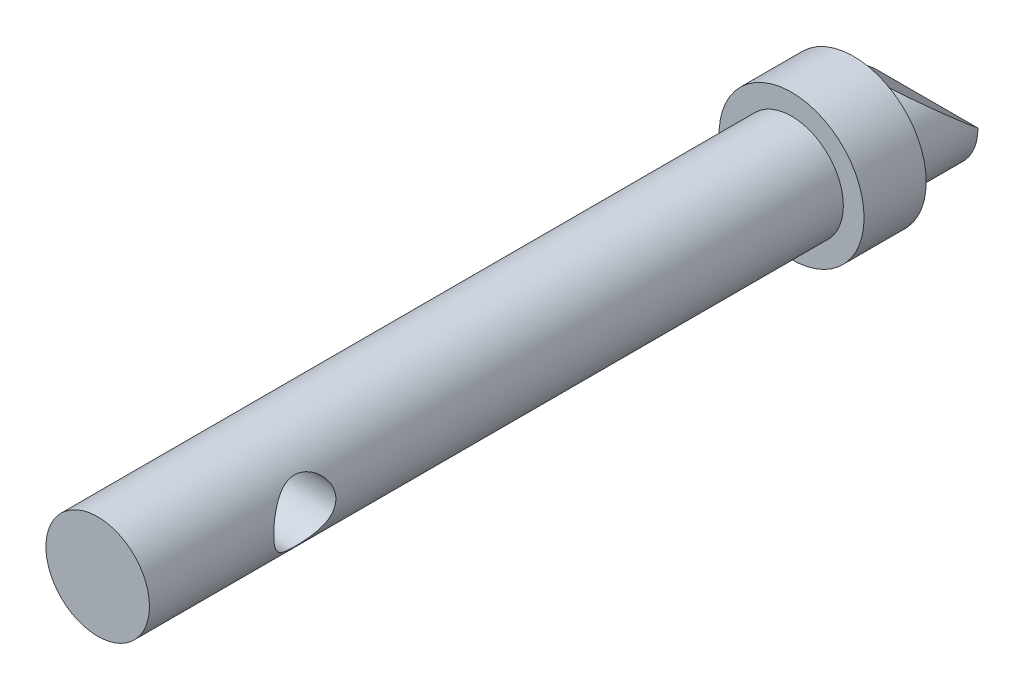
from build123d import *

# Parameters (mm, degrees)
SKETCH1_R                = 2.5
BOSS_EXTRUDE1_DEPTH      = 35
BOSS_EXTRUDE1_DEPTH_BACK = 5
SKETCH2_R                = 3.5
BOSS_EXTRUDE2_DEPTH      = 1.5
BOSS_EXTRUDE2_DEPTH_BACK = 1.5
SKETCH3_R                = 1.5
CUT_EXTRUDE1_DEPTH       = 4.5
CUT_EXTRUDE1_DEPTH_BACK  = 4.5
CUT_EXTRUDE2_DEPTH       = 4.5
CUT_EXTRUDE2_DEPTH_BACK  = 4.5


with BuildPart() as part:
    # Sketch1 → Boss-Extrude1 (new body, two sides)
    with BuildSketch(Plane.XY) as boss_extrude1_sk:
        Circle(SKETCH1_R)
    extrude(amount=BOSS_EXTRUDE1_DEPTH)
    extrude(boss_extrude1_sk.sketch, amount=-BOSS_EXTRUDE1_DEPTH_BACK)

    # Sketch2 → Boss-Extrude2 (add, two sides)
    with BuildSketch(Plane.XY) as boss_extrude2_sk:
        Circle(SKETCH2_R)
    extrude(amount=BOSS_EXTRUDE2_DEPTH)
    extrude(boss_extrude2_sk.sketch, amount=-BOSS_EXTRUDE2_DEPTH_BACK)

    # Sketch3 → Cut-Extrude1 (cut, two sides)
    with BuildSketch(Plane(origin=(0, 0, 0), x_dir=(0, 0, -1), z_dir=(1, 0, 0))) as cut_extrude1_sk:
        with Locations((-27.5, 0)):
            Circle(SKETCH3_R)
    extrude(amount=CUT_EXTRUDE1_DEPTH, mode=Mode.SUBTRACT)
    extrude(cut_extrude1_sk.sketch, amount=-CUT_EXTRUDE1_DEPTH_BACK, mode=Mode.SUBTRACT)

    # Sketch4 → Cut-Extrude2 (cut, two sides)
    with BuildSketch(Plane(origin=(0, 0, 0), x_dir=(0, 0, -1), z_dir=(1, 0, 0))) as cut_extrude2_sk:
        Polygon((5, 0), (2, 2.5), (5, 2.5), align=None)
    extrude(amount=CUT_EXTRUDE2_DEPTH, mode=Mode.SUBTRACT)
    extrude(cut_extrude2_sk.sketch, amount=-CUT_EXTRUDE2_DEPTH_BACK, mode=Mode.SUBTRACT)


solid = part.part
